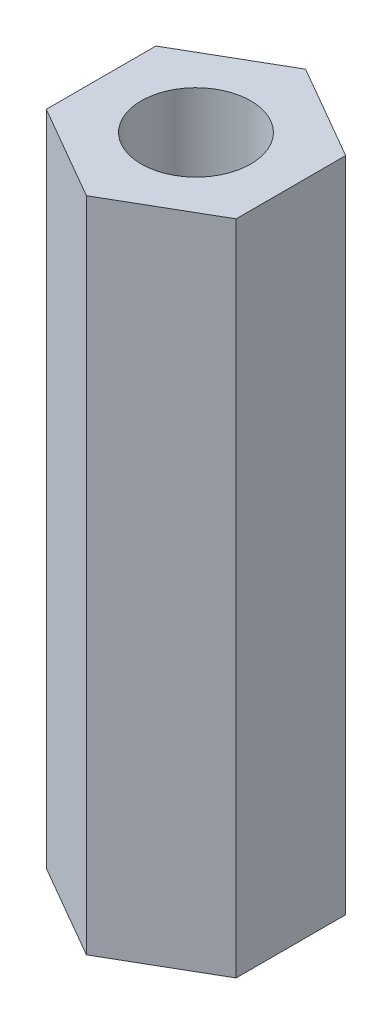
from build123d import *

# Parameters (mm, degrees)
ESQUISSE1_R      = 2.5
EXTRUSION1_DEPTH = 30


with BuildPart() as part:
    # Esquisse1 → Extrusion1 (new body)
    with BuildSketch(Plane(origin=(0, 0, 0), x_dir=(1, 0, 0), z_dir=(0, 1, 0))):
        Polygon((0, 5), (-4.330127019, 2.5), (-4.330127019, -2.5), (0, -5), (4.330127019, -2.5), (4.330127019, 2.5), align=None)
        Circle(ESQUISSE1_R, mode=Mode.SUBTRACT)
    extrude(amount=EXTRUSION1_DEPTH)


solid = part.part
